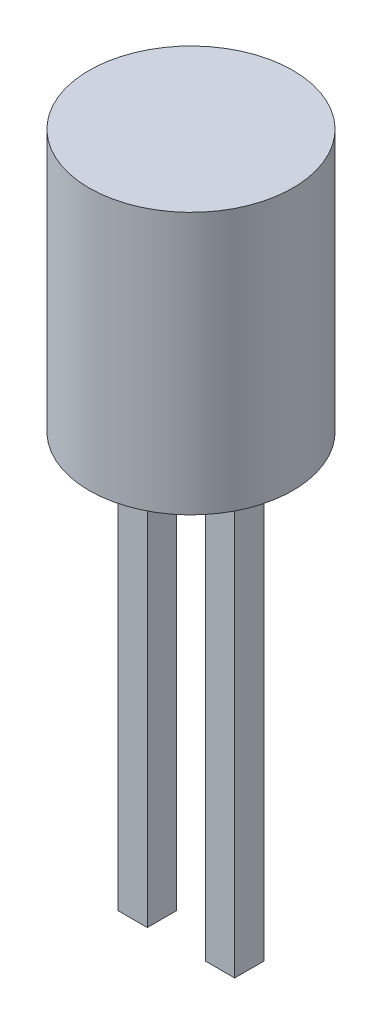
from build123d import *

# Parameters (mm, degrees)
SKETCH1_R           = 3.5
BOSS_EXTRUDE1_DEPTH = 9
SKETCH2_W           = 1
SKETCH2_H           = 1
BOSS_EXTRUDE2_DEPTH = 24


with BuildPart() as part:
    # Sketch1 → Boss-Extrude1 (new body)
    with BuildSketch(Plane(origin=(0, 0, 0), x_dir=(1, 0, 0), z_dir=(0, 1, 0))):
        Circle(SKETCH1_R)
    extrude(amount=BOSS_EXTRUDE1_DEPTH)

    # Sketch2 → Boss-Extrude2 (add)
    with BuildSketch(Plane(origin=(0, 9, 0), x_dir=(1, 0, 0), z_dir=(0, 1, 0))):
        with Locations((-1.5, 0)):
            Rectangle(SKETCH2_W, SKETCH2_H)
        with Locations((1.5, 0)):
            Rectangle(SKETCH2_W, SKETCH2_H)
    extrude(amount=-BOSS_EXTRUDE2_DEPTH)


solid = part.part
